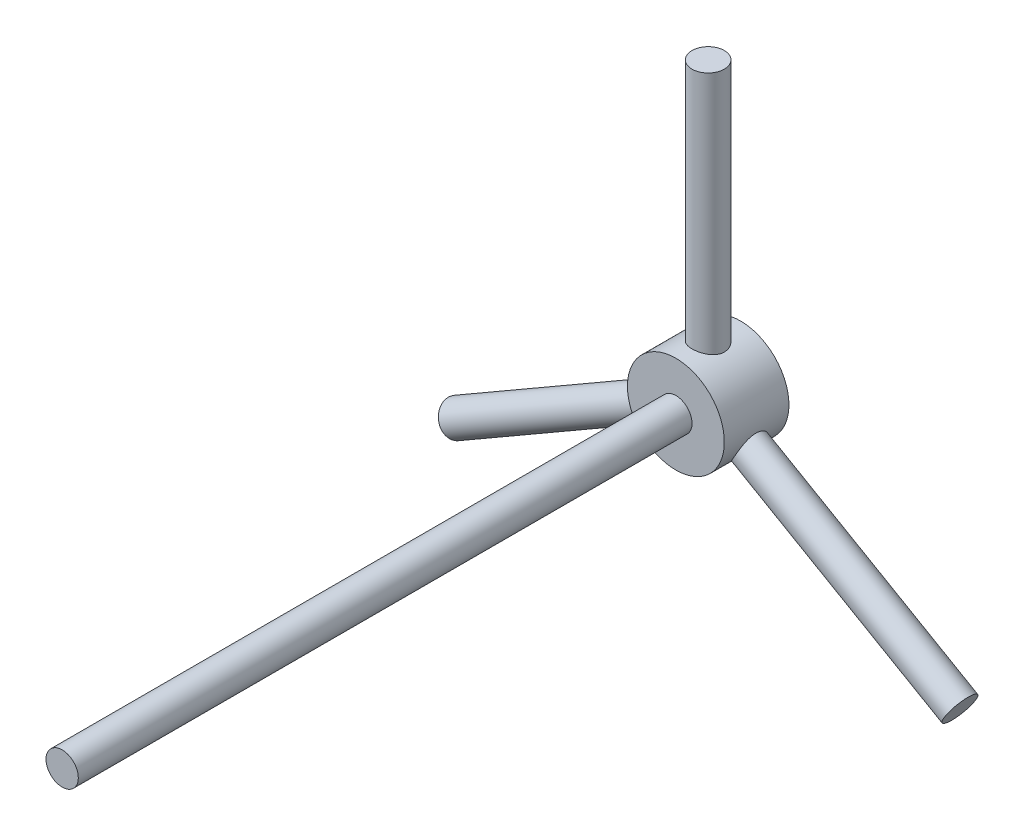
from build123d import *

# Parameters (mm, degrees)
SKETCH_1_R      = 5
EXTRUDE_1_DEPTH = 70
SKETCH_2_R      = 5
EXTRUDE_2_DEPTH = 50
SKETCH_3_R      = 15
EXTRUDE_3_DEPTH = 20
SKETCH_4_R      = 5
EXTRUDE_4_DEPTH = 90
SKETCH_8_R      = 5
EXTRUDE_5_DEPTH = 90
SKETCH_9_R      = 5
EXTRUDE_6_DEPTH = 90


with BuildPart() as part:
    # 草图1 → 凸台-拉伸1 (new, symmetric)
    with BuildSketch(Plane.XY):
        Circle(SKETCH_1_R)
    extrude(amount=EXTRUDE_1_DEPTH, both=True)

    # 草图2 → 凸台-拉伸2 (add)
    with BuildSketch(Plane(origin=(0, 0, -70), x_dir=(-1, 0, 0), z_dir=(0, 0, -1))):
        Circle(SKETCH_2_R)
    extrude(amount=EXTRUDE_2_DEPTH)

    # 草图3 → 凸台-拉伸3 (add)
    with BuildSketch(Plane(origin=(0, 0, -120), x_dir=(-1, 0, 0), z_dir=(0, 0, -1))):
        Circle(SKETCH_3_R)
    extrude(amount=EXTRUDE_3_DEPTH)

    # 草图4 → 凸台-拉伸4 (add)
    with BuildSketch(Plane(origin=(0, 0, 0), x_dir=(1, 0, 0), z_dir=(0, 1, 0))):
        with Locations((0, 130)):
            Circle(SKETCH_4_R)
    extrude(amount=EXTRUDE_4_DEPTH)

    # 草图8 → 凸台-拉伸5 (add)
    with BuildSketch(Plane(origin=(0, 0, 0), x_dir=(0, 0, -1), z_dir=(0.8660254037844363, -0.5000000000000042, 0))):
        with Locations((130, 0)):
            Circle(SKETCH_8_R)
    extrude(amount=EXTRUDE_5_DEPTH)

    # 草图9 → 凸台-拉伸6 (add)
    with BuildSketch(Plane(origin=(0, 0, 0), x_dir=(0, 0, 1), z_dir=(-0.8660254037844365, -0.500000000000004, 0))):
        with Locations((-130, 0)):
            Circle(SKETCH_9_R)
    extrude(amount=EXTRUDE_6_DEPTH)


solid = part.part
